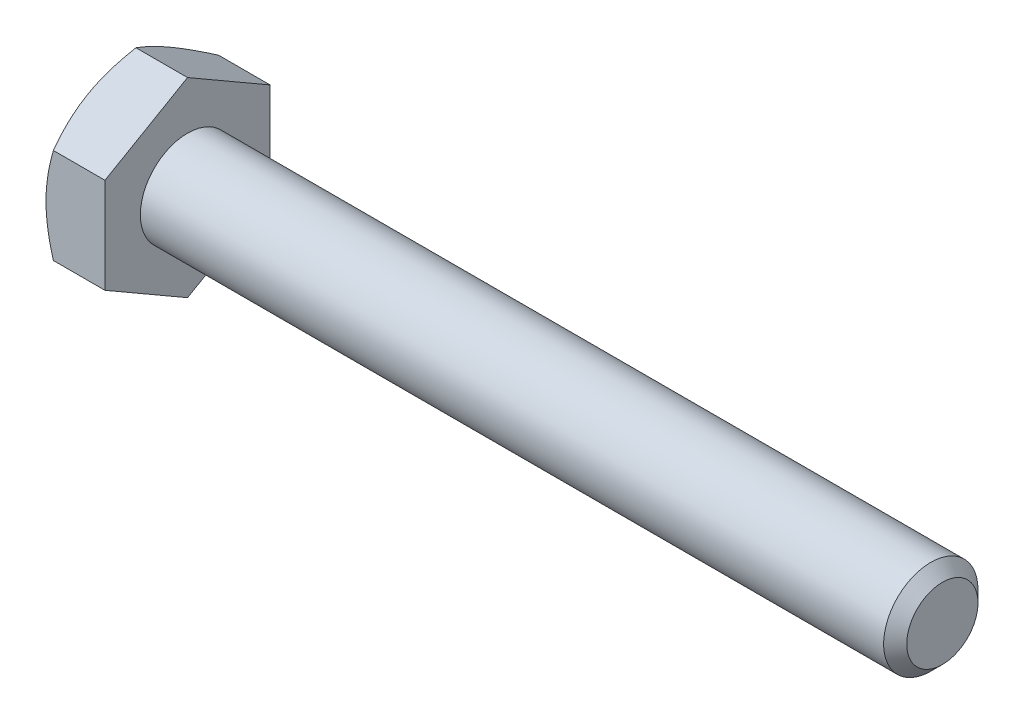
from build123d import *

# Parameters (mm, degrees)
SKETCH5_R           = 3.175
BOSS_EXTRUDE3_DEPTH = 50.8
CHAMFER1_SIZE       = 0.77724
BOSS_EXTRUDE4_DEPTH = 3.96875
SKETCH8_OUTSIDE_W   = 217.768
SKETCH8_OUTSIDE_H   = 219.488
SKETCH8_OUTSIDE_R   = 5.55625
CUT_EXTRUDE3_DEPTH  = 55.76875
CUT_EXTRUDE3_TAPER  = 60
CUT_EXTRUDE4_DEPTH  = 0.254
CIRPATTERN1_COUNT   = 3


with BuildPart() as part:
    # Sketch5 → Boss-Extrude3 (new body)
    with BuildSketch(Plane(origin=(27.384375, 0, 0), x_dir=(0, 0, -1), z_dir=(1, 0, 0))):
        Circle(SKETCH5_R)
    extrude(amount=-BOSS_EXTRUDE3_DEPTH)

    # Chamfer1
    chamfer1_edges = [part.edges().sort_by_distance(p)[0] for p in [
        (27.384375, 0, 3.175),
    ]]
    chamfer(chamfer1_edges, length=CHAMFER1_SIZE)

    # Sketch6 → Boss-Extrude4 (add)
    with BuildSketch(Plane.ZY.offset(23.415625)):
        Polygon((5.55625, 3.207902433), (0, 6.415804866), (-5.55625, 3.207902433), (-5.55625, -3.207902433), (0, -6.415804866), (5.55625, -3.207902433), align=None)
    extrude(amount=BOSS_EXTRUDE4_DEPTH)

    # Sketch8 outside → Cut-Extrude3 (cut, through all)
    with BuildSketch(Plane.ZY.offset(27.384375)):
        Rectangle(SKETCH8_OUTSIDE_W, SKETCH8_OUTSIDE_H)
        Circle(SKETCH8_OUTSIDE_R, mode=Mode.SUBTRACT)
    extrude(amount=-CUT_EXTRUDE3_DEPTH, taper=CUT_EXTRUDE3_TAPER, mode=Mode.SUBTRACT)

    # Sketch12 → Cut-Extrude4 (cut)
    with BuildSketch(Plane.ZY.offset(27.384375)):
        with BuildLine():
            Line((0.1666875, 4.2783125), (0.1666875, 2.3891875))
            ThreePointArc((0.1666875, 2.3891875), (0, 2.2225), (-0.1666875, 2.3891875))
            Line((-0.1666875, 2.3891875), (-0.1666875, 4.2783125))
            ThreePointArc((-0.1666875, 4.2783125), (0, 4.445), (0.1666875, 4.2783125))
        make_face()
    cut_extrude4 = extrude(amount=-CUT_EXTRUDE4_DEPTH, mode=Mode.SUBTRACT)

    # CirPattern1: Cut-Extrude4 ×3 about axis
    cirpattern1_axis = Axis((0, 0, 0), (1, 0, 0))
    for i in range(1, CIRPATTERN1_COUNT):
        add(cut_extrude4.rotate(cirpattern1_axis, i * 360 / CIRPATTERN1_COUNT), mode=Mode.SUBTRACT)


solid = part.part
